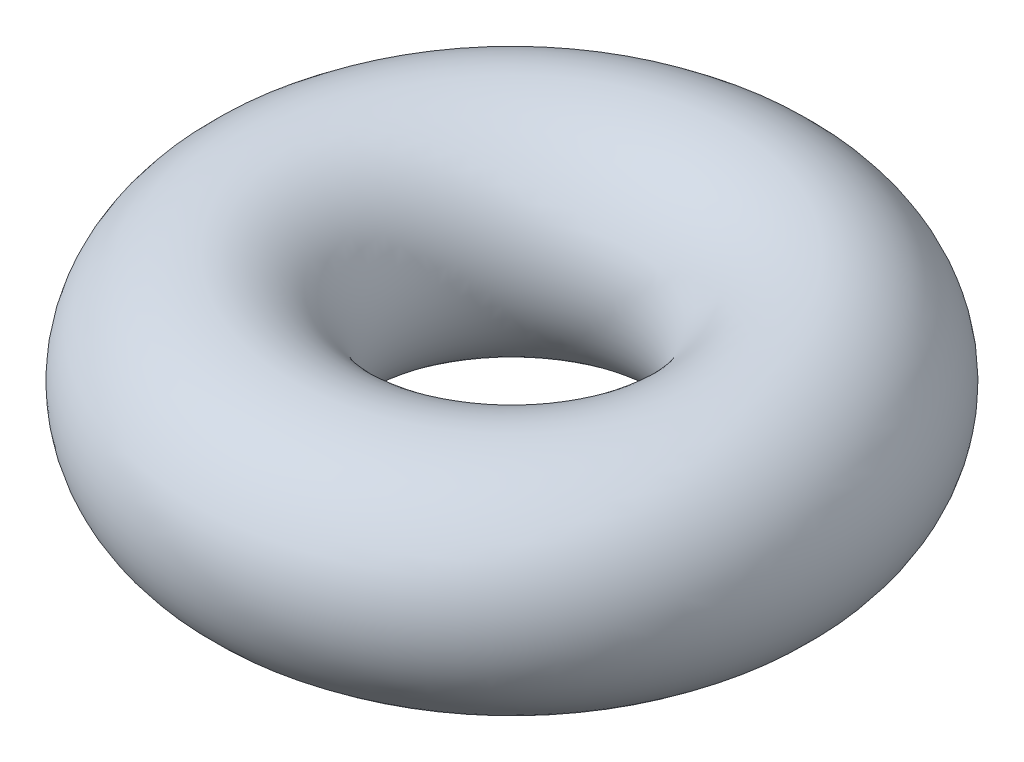
from build123d import *

# Parameters (mm, degrees)
SKETCH2_R = 60.5


with BuildPart() as part:
    # Sketch2 → Revolve2 (revolve)
    with BuildSketch(Plane.XY):
        with Locations((-121, 0)):
            Circle(SKETCH2_R)
    revolve(axis=Axis((0, 0, 0), (0, 1, 0)))


solid = part.part
